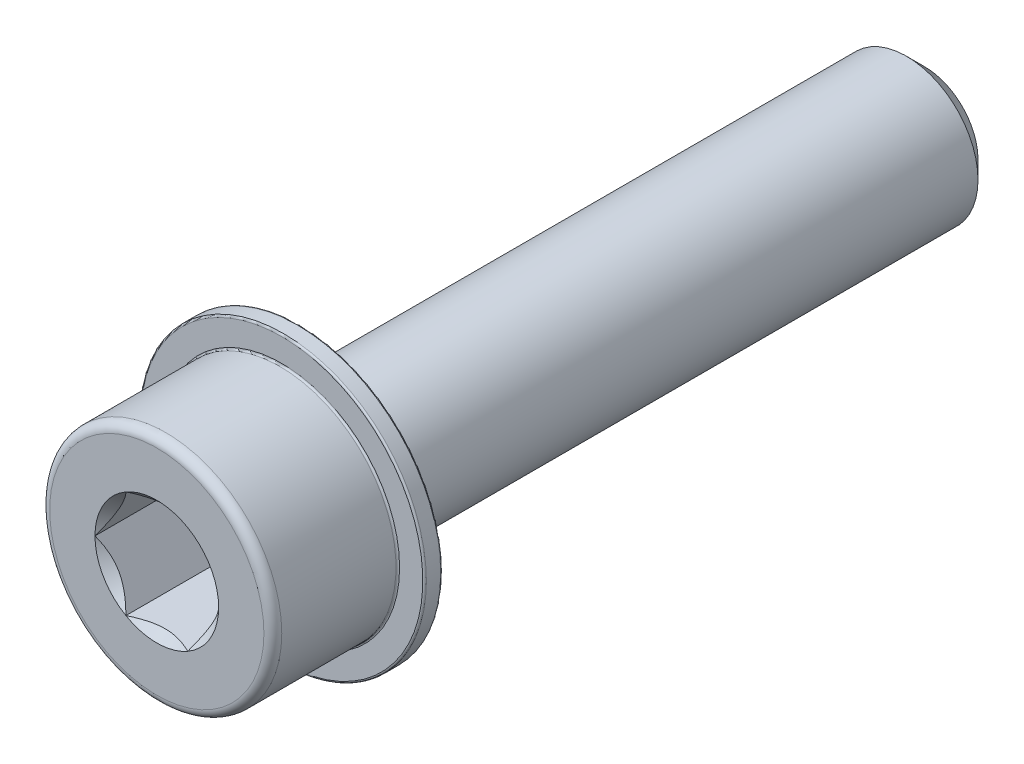
from build123d import *

# Parameters (mm, degrees)
SCHIZZO1_R                   = 4
ESTRUSIONE_ESTRUSIONE1_DEPTH = 35
SMUSSO1_SIZE                 = 1
SCHIZZO6_R                   = 6.5
ESTRUSIONE_ESTRUSIONE3_DEPTH = 8
TAGLIO_ESTRUSIONE3_DEPTH     = 6
SCHIZZO8_R                   = 3.464101615
TAGLIO_ESTRUSIONE4_DEPTH     = 1
TAGLIO_ESTRUSIONE4_TAPER     = 45
RACCORDO1_R                  = 0.5
SCHIZZO9_R                   = 8
SCHIZZO9_R_2                 = 6.5
ESTRUSIONE_ESTRUSIONE4_DEPTH = 1
RACCORDO2_R                  = 0.1


with BuildPart() as part:
    # Schizzo1 → Estrusione-Estrusione1 (new body)
    with BuildSketch(Plane.XY):
        Circle(SCHIZZO1_R)
    extrude(amount=ESTRUSIONE_ESTRUSIONE1_DEPTH)

    # Smusso1
    smusso1_edges = [part.edges().sort_by_distance(p)[0] for p in [
        (-4, 0, 0),
    ]]
    chamfer(smusso1_edges, length=SMUSSO1_SIZE)

    # Schizzo6 → Estrusione-Estrusione3 (add)
    with BuildSketch(Plane.XY.offset(35)):
        Circle(SCHIZZO6_R)
    extrude(amount=ESTRUSIONE_ESTRUSIONE3_DEPTH)

    # Schizzo7 → Taglio-Estrusione3 (cut)
    with BuildSketch(Plane.XY.offset(43)):
        Polygon((1.732050808, 3), (-1.732050808, 3), (-3.464101615, 0), (-1.732050808, -3), (1.732050808, -3), (3.464101615, 0), align=None)
    extrude(amount=-TAGLIO_ESTRUSIONE3_DEPTH, mode=Mode.SUBTRACT)

    # Schizzo8 → Taglio-Estrusione4 (cut)
    with BuildSketch(Plane.XY.offset(43)):
        Circle(SCHIZZO8_R)
    extrude(amount=-TAGLIO_ESTRUSIONE4_DEPTH, taper=TAGLIO_ESTRUSIONE4_TAPER, mode=Mode.SUBTRACT)

    # Raccordo1
    raccordo1_edges = [part.edges().sort_by_distance(p)[0] for p in [
        (-6.5, 0, 43),
    ]]
    fillet(raccordo1_edges, radius=RACCORDO1_R)

    # Schizzo9 → Estrusione-Estrusione4 (add)
    with BuildSketch(Plane(origin=(0, 0, 35), x_dir=(-1, 0, 0), z_dir=(0, 0, -1))):
        Circle(SCHIZZO9_R)
        Circle(SCHIZZO9_R_2, mode=Mode.SUBTRACT)
    extrude(amount=-ESTRUSIONE_ESTRUSIONE4_DEPTH)

    # Raccordo2
    raccordo2_edges = [part.edges().sort_by_distance(p)[0] for p in [
        (-6.5, 0, 36),
        (8, 0, 36),
        (8, 0, 35),
    ]]
    fillet(raccordo2_edges, radius=RACCORDO2_R)


solid = part.part
